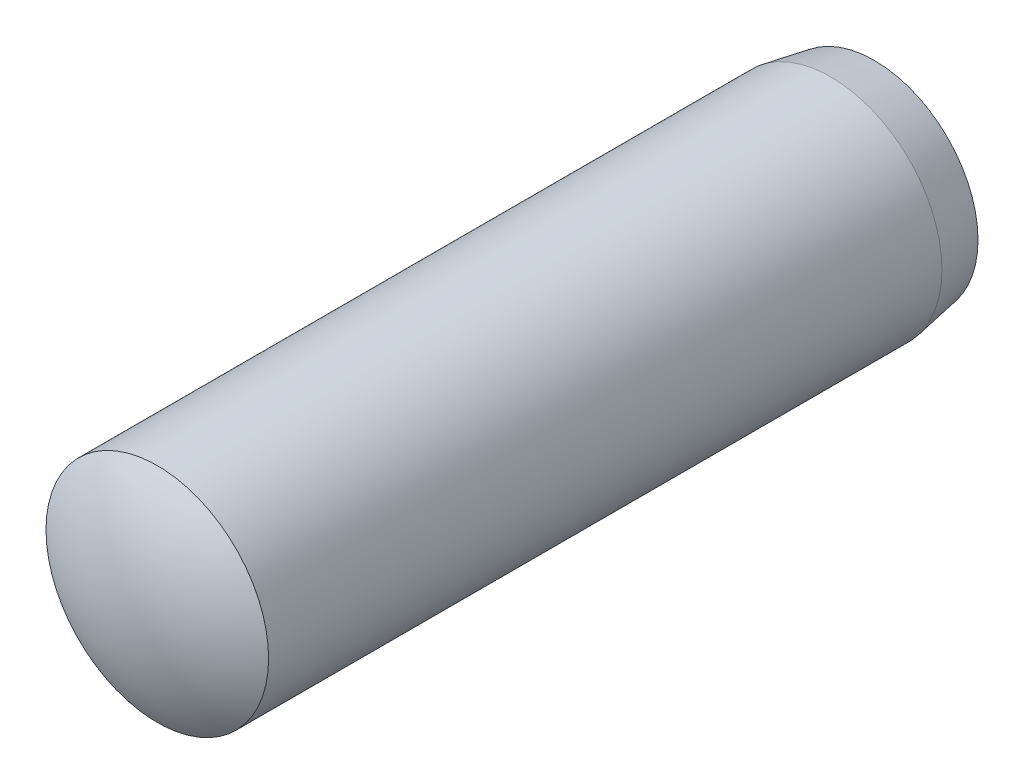
from build123d import *


with BuildPart() as part:
    # Skizze1 → Rotation1 (revolve)
    with BuildSketch(Plane(origin=(0, 0, 0), x_dir=(1, 0, 0), z_dir=(0, 1, 0))):
        with BuildLine():
            Line((0, 14), (0, -14))
            ThreePointArc((0, -14), (-2.088061302, -13.693537673), (-4, -12.8))
            Line((-4, -12.8), (-4, 11.4))
            Line((-4, 11.4), (-3.722432826, 12.974161668))
            ThreePointArc((-3.722432826, 12.974161668), (-1.930599028, 13.738847721), (0, 14))
        make_face()
    revolve(axis=Axis((0, 0, -14), (0, 0, 1)))


solid = part.part
